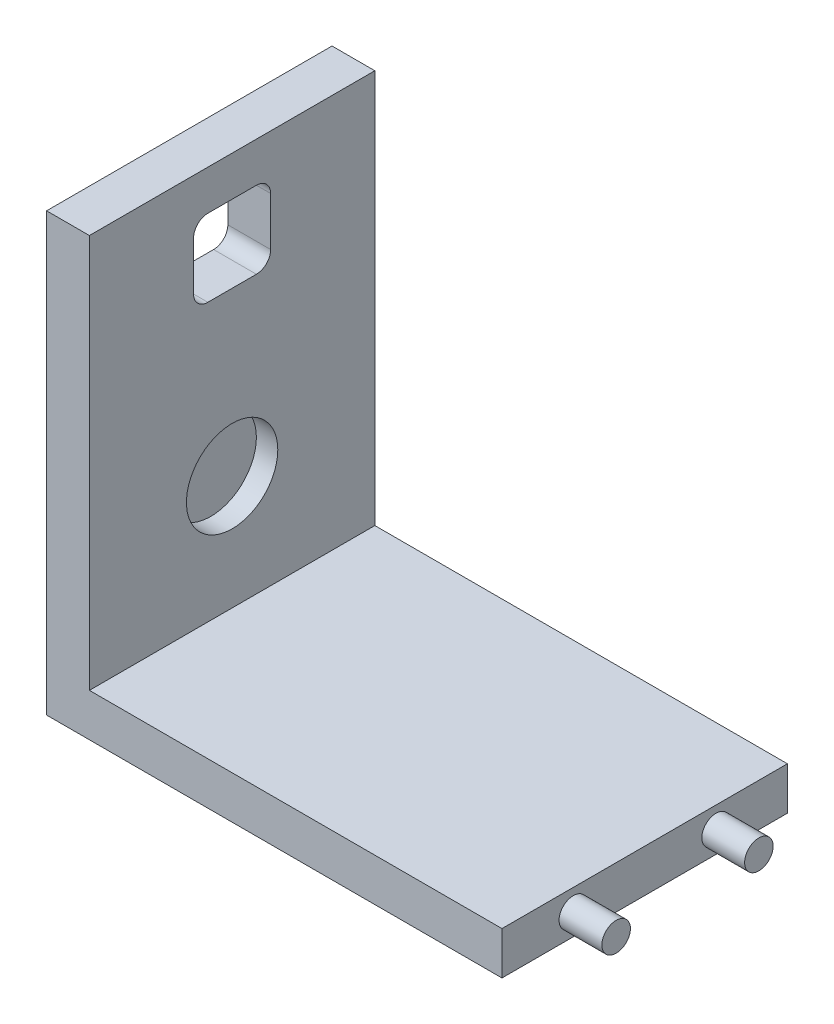
from build123d import *

# Parameters (mm, degrees)
Y_KSEKLIK_EKSTR_ZYON1_DEPTH = 100
IZIM4_R                     = 5
Y_KSEKLIK_EKSTR_ZYON2_DEPTH = 15
IZIM2_R                     = 16
KES_EKSTR_ZYON7_DEPTH       = 7.5
KES_EKSTR_ZYON8_DEPTH       = 16


with BuildPart() as part:
    # Çizim1 → Yükseklik-Ekstrüzyon1 (new body)
    with BuildSketch(Plane.XY):
        Polygon((-87.26990817, 0), (72.26990817, 0), (72.26990817, 15), (-72.26990817, 15), (-72.26990817, 153), (-87.26990817, 153), align=None)
    extrude(amount=-Y_KSEKLIK_EKSTR_ZYON1_DEPTH)

    # Çizim4 → Yükseklik-Ekstrüzyon2 (add)
    with BuildSketch(Plane(origin=(72.26990817, 0, 0), x_dir=(0, 0, -1), z_dir=(1, 0, 0))):
        with Locations((25, 7.5)):
            Circle(IZIM4_R)
        with Locations((75, 7.5)):
            Circle(IZIM4_R)
    extrude(amount=Y_KSEKLIK_EKSTR_ZYON2_DEPTH)

    # Çizim2 → Kes-Ekstrüzyon7 (cut)
    with BuildSketch(Plane(origin=(-72.26990817, 0, 0), x_dir=(0, 0, -1), z_dir=(1, 0, 0))):
        with Locations((50, 55)):
            Circle(IZIM2_R)
    extrude(amount=-KES_EKSTR_ZYON7_DEPTH, mode=Mode.SUBTRACT)

    # Çizim3 → Kes-Ekstrüzyon8 (cut, through all)
    with BuildSketch(Plane(origin=(-72.26990817, 0, 0), x_dir=(0, 0, -1), z_dir=(1, 0, 0))):
        with BuildLine():
            Line((41.5, 139), (58.5, 139))
            ThreePointArc((58.5, 139), (62.035533906, 137.535533906), (63.5, 134))
            Line((63.5, 134), (63.5, 117))
            ThreePointArc((63.5, 117), (62.035533906, 113.464466094), (58.5, 112))
            Line((58.5, 112), (41.5, 112))
            ThreePointArc((41.5, 112), (37.964466094, 113.464466094), (36.5, 117))
            Line((36.5, 117), (36.5, 134))
            ThreePointArc((36.5, 134), (37.964466094, 137.535533906), (41.5, 139))
        make_face()
    extrude(amount=-KES_EKSTR_ZYON8_DEPTH, mode=Mode.SUBTRACT)


solid = part.part
